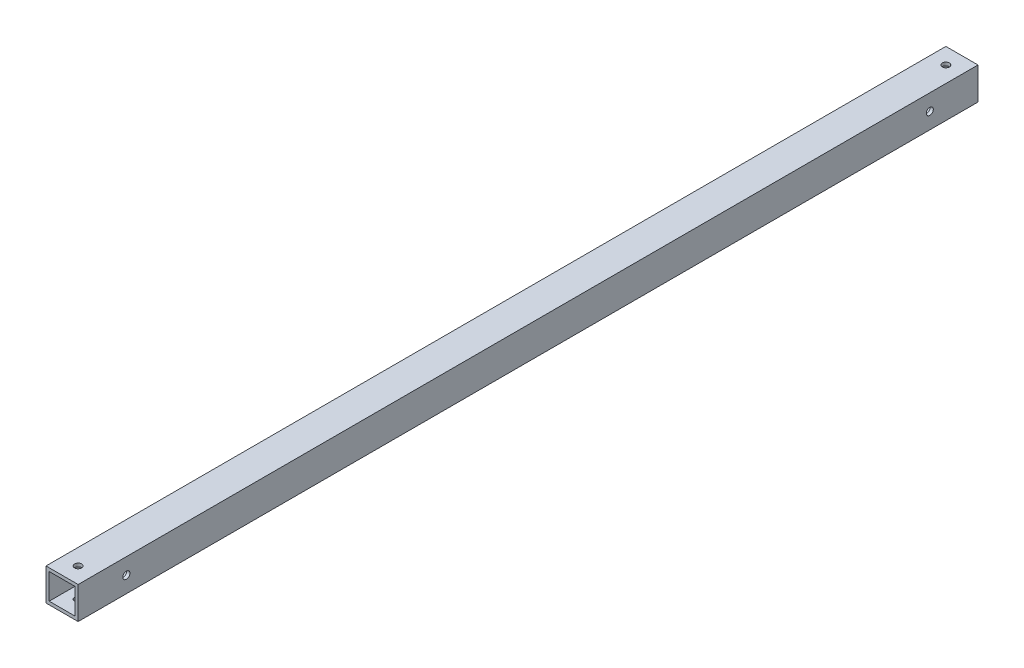
from build123d import *

# Parameters (mm, degrees)
SKETCH_1_W          = 20
SKETCH_1_H          = 20
SKETCH_1_W_2        = 16
SKETCH_1_H_2        = 16
EXTRUDE_1_DEPTH     = 560
SKETCH_3_R          = 2.2
CUT_EXTRUDE_2_DEPTH = 560
SKETCH_4_R          = 2.2
CUT_EXTRUDE_3_DEPTH = 560


with BuildPart() as part:
    # ｽｹｯﾁ1 → ﾎﾞｽ - 押し出し1 (new body)
    with BuildSketch(Plane.XY):
        Rectangle(SKETCH_1_W, SKETCH_1_H)
        Rectangle(SKETCH_1_W_2, SKETCH_1_H_2, mode=Mode.SUBTRACT)
    extrude(amount=EXTRUDE_1_DEPTH)

    # ｽｹｯﾁ3 → ｶｯﾄ - 押し出し2 (cut)
    with BuildSketch(Plane(origin=(10, 0, 0), x_dir=(0, 0, -1), z_dir=(1, 0, 0))):
        with Locations((-530, 0)):
            Circle(SKETCH_3_R)
        with Locations((-30, 0)):
            Circle(SKETCH_3_R)
    extrude(amount=-CUT_EXTRUDE_2_DEPTH, mode=Mode.SUBTRACT)

    # ｽｹｯﾁ4 → ｶｯﾄ - 押し出し3 (cut)
    with BuildSketch(Plane(origin=(0, 10, 0), x_dir=(1, 0, 0), z_dir=(0, 1, 0))):
        with Locations((0, -550)):
            Circle(SKETCH_4_R)
        with Locations((0, -10)):
            Circle(SKETCH_4_R)
    extrude(amount=-CUT_EXTRUDE_3_DEPTH, mode=Mode.SUBTRACT)


solid = part.part
